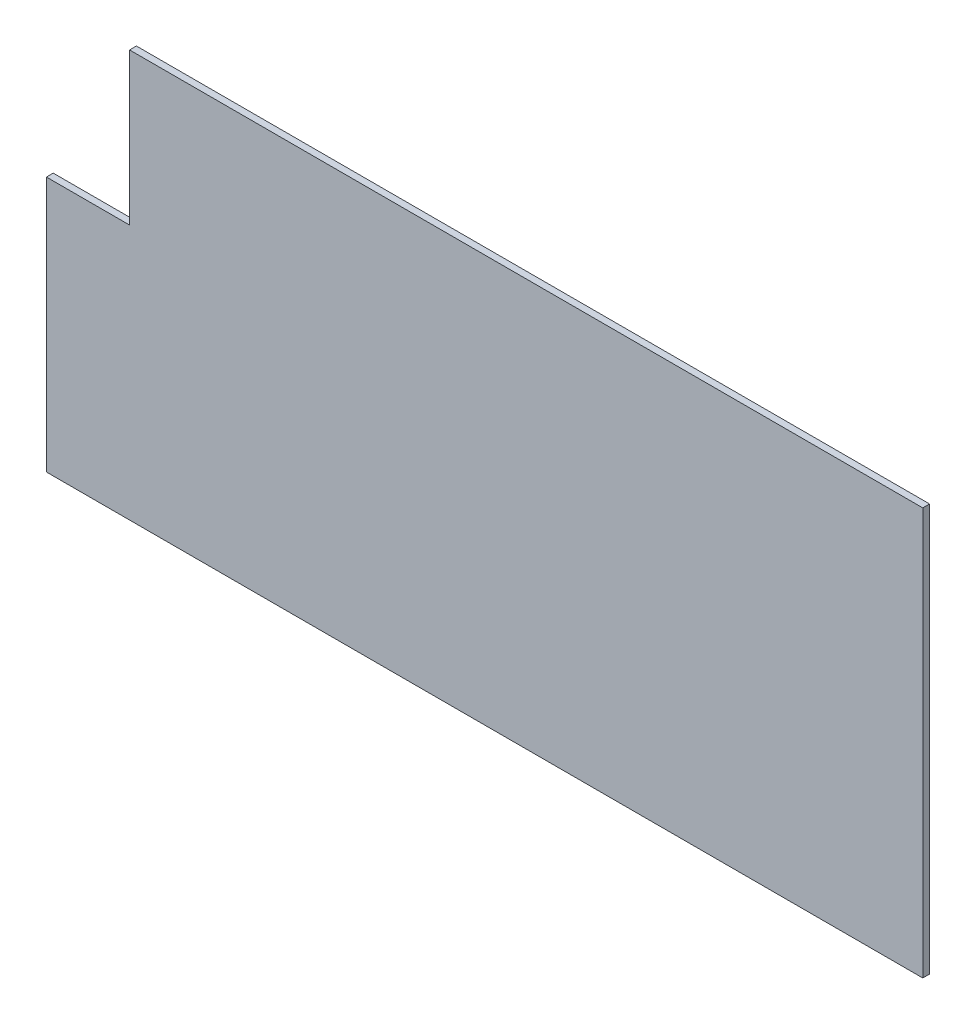
from build123d import *

# Parameters (mm, degrees)
SKETCH1_W           = 579
SKETCH1_H           = 269
BOSS_EXTRUDE1_DEPTH = 2.2479
SKETCH2_W           = 54.949993563
SKETCH2_H           = 100.2
CUT_EXTRUDE1_DEPTH  = 4.4958


with BuildPart() as part:
    # Sketch1 → Boss-Extrude1 (new body, symmetric)
    with BuildSketch(Plane.XY):
        Rectangle(SKETCH1_W, SKETCH1_H)
    extrude(amount=BOSS_EXTRUDE1_DEPTH, both=True)

    # Sketch2 → Cut-Extrude1 (cut)
    with BuildSketch(Plane(origin=(0, 0, -2.2479), x_dir=(-1, 0, 0), z_dir=(0, 0, -1))):
        with Locations((262.025003218, 84.4)):
            Rectangle(SKETCH2_W, SKETCH2_H)
    extrude(amount=-CUT_EXTRUDE1_DEPTH, mode=Mode.SUBTRACT)


solid = part.part
